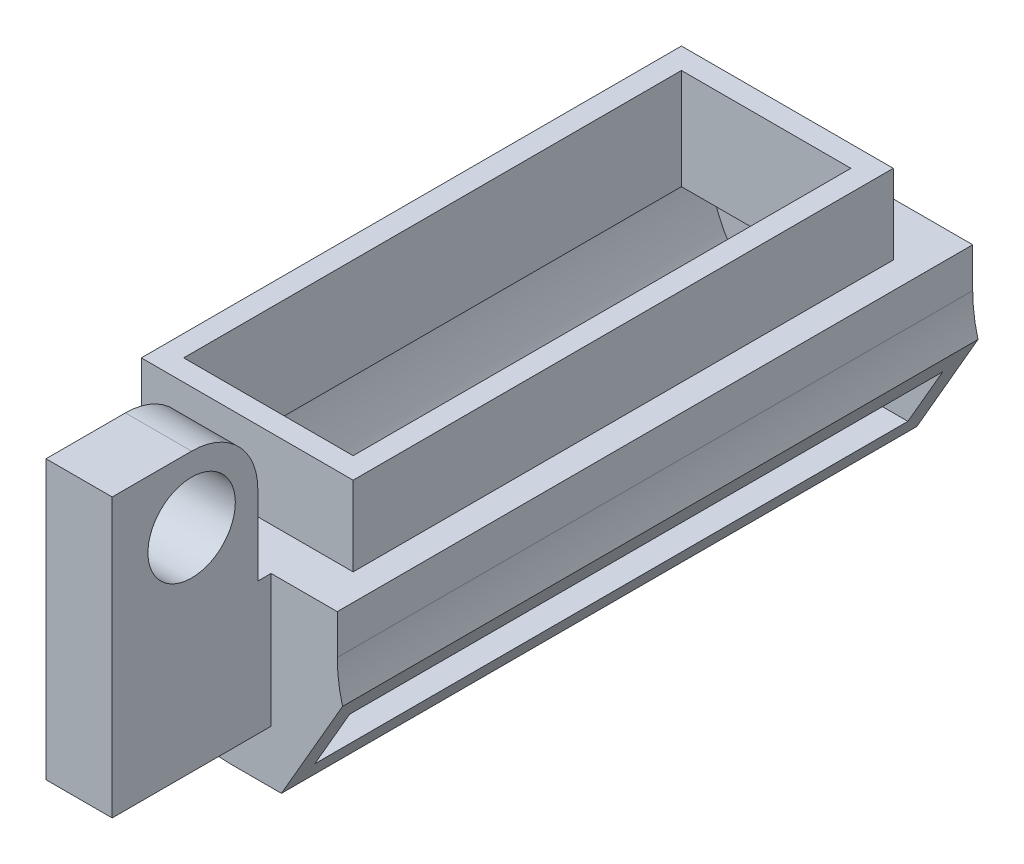
from build123d import *

# Parameters (mm, degrees)
RESSALTO_EXTRUS_O1_DEPTH = 12
ESBO_O4_W                = 8
ESBO_O4_H                = 20.4
RESSALTO_EXTRUS_O2_DEPTH = 3
CASCA2_T                 = -0.8
ESBO_O5_R                = 1.65
RESSALTO_EXTRUS_O3_DEPTH = 2.5


with BuildPart() as part:
    # Esboço1 → Ressalto-extrusão1 (new body, symmetric)
    with BuildSketch(Plane.XY):
        with BuildLine():
            Line((-5, 0), (5, 0))
            Line((5, 0), (5, -1.5))
            ThreePointArc((5, -1.5), (5.050220269, -2.256637298), (5.2, -3))
            Line((5.2, -3), (2.890598923, -7))
            Line((2.890598923, -7), (1, -7))
            ThreePointArc((1, -7), (-3.242640687, -5.242640687), (-5, -1))
            Line((-5, -1), (-5, 0))
        make_face()
    extrude(amount=RESSALTO_EXTRUS_O1_DEPTH, both=True)

    # Esboço4 → Ressalto-extrusão2 (add)
    with BuildSketch(Plane(origin=(0, 0, 0), x_dir=(1, 0, 0), z_dir=(0, 1, 0))):
        with Locations((0, -0.2)):
            Rectangle(ESBO_O4_W, ESBO_O4_H)
    extrude(amount=RESSALTO_EXTRUS_O2_DEPTH)

    # Casca2
    casca2_openings = [part.faces().sort_by_distance(p)[0] for p in [
        (4.045299462, -5, 0),
        (0, 3, 0.2),
    ]]
    offset(amount=CASCA2_T, openings=casca2_openings, kind=Kind.INTERSECTION)

    # Esboço5 → Ressalto-extrusão3 (add)
    with BuildSketch(Plane(origin=(0, 0, 0), x_dir=(0, 0, -1), z_dir=(1, 0, 0))):
        with BuildLine():
            Line((-12, 0), (-12.5, 0))
            Line((-12.5, 0), (-12.5, 3))
            ThreePointArc((-12.5, 3), (-13.232233047, 4.767766953), (-15, 5.5))
            Line((-15, 5.5), (-18, 5.5))
            Line((-18, 5.5), (-18, -5))
            Line((-18, -5), (-12, -5))
            Line((-12, -5), (-12, 0))
        make_face()
        with Locations((-15, 3)):
            Circle(ESBO_O5_R, mode=Mode.SUBTRACT)
    extrude(amount=RESSALTO_EXTRUS_O3_DEPTH)


solid = part.part
